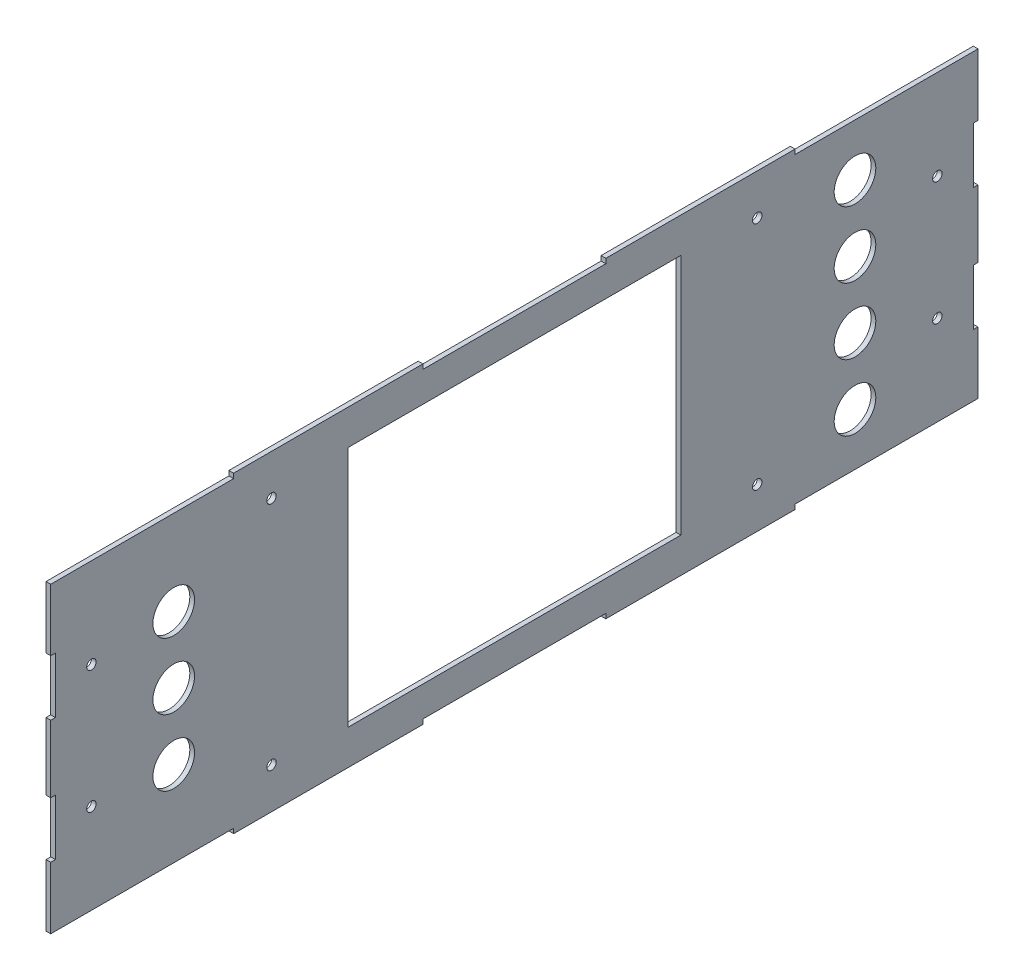
from build123d import *

# Parameters (mm, degrees)
BOSS_EXTRUDE1_DEPTH = 2.5
SKETCH2_R           = 2.5
SKETCH2_R_2         = 11
SKETCH2_W           = 2.5
SKETCH2_H           = 29.5
SKETCH2_W_2         = 176
SKETCH2_H_2         = 128
CUT_EXTRUDE1_DEPTH  = 3


with BuildPart() as part:
    # Sketch1 → Boss-Extrude1 (new body)
    with BuildSketch(Plane(origin=(0, 0, 0), x_dir=(0, 0, -1), z_dir=(1, 0, 0))):
        Polygon((-245, -80), (-148.333333333, -80), (-148.333333333, -82.5), (-48.333333333, -82.5), (-48.333333333, -80), (48.333333333, -80), (48.333333333, -82.5), (148.333333333, -82.5), (148.333333333, -80), (245, -80), (245, 80), (148.333333333, 80), (148.333333333, 82.5), (48.333333333, 82.5), (48.333333333, 80), (-48.333333333, 80), (-48.333333333, 82.5), (-148.333333333, 82.5), (-148.333333333, 80), (-245, 80), align=None)
    extrude(amount=BOSS_EXTRUDE1_DEPTH)

    # Sketch2 → Cut-Extrude1 (cut)
    with BuildSketch(Plane(origin=(2.5, 0, 0), x_dir=(0, 0, -1), z_dir=(1, 0, 0))):
        with Locations((-128.333333333, 61)):
            Circle(SKETCH2_R)
        with Locations((128.333333333, 61)):
            Circle(SKETCH2_R)
        with Locations((128.333333333, -61)):
            Circle(SKETCH2_R)
        with Locations((-128.333333333, -61)):
            Circle(SKETCH2_R)
        with Locations((-223.5, 32.5)):
            Circle(SKETCH2_R)
        with Locations((-223.5, -32.5)):
            Circle(SKETCH2_R)
        with Locations((223.5, 32.5)):
            Circle(SKETCH2_R)
        with Locations((223.5, -32.5)):
            Circle(SKETCH2_R)
        with Locations((-180, 35)):
            Circle(SKETCH2_R_2)
        with Locations((-180, 0)):
            Circle(SKETCH2_R_2)
        with Locations((-180, -35)):
            Circle(SKETCH2_R_2)
        with Locations((180, 17.5)):
            Circle(SKETCH2_R_2)
        with Locations((180, 52.5)):
            Circle(SKETCH2_R_2)
        with Locations((180, -17.5)):
            Circle(SKETCH2_R_2)
        with Locations((180, -52.5)):
            Circle(SKETCH2_R_2)
        with Locations((-243.75, 32.5)):
            Rectangle(SKETCH2_W, SKETCH2_H)
        with Locations((-243.75, -32.5)):
            Rectangle(SKETCH2_W, SKETCH2_H)
        with Locations((243.75, -32.5)):
            Rectangle(SKETCH2_W, SKETCH2_H)
        with Locations((243.75, 32.5)):
            Rectangle(SKETCH2_W, SKETCH2_H)
        Rectangle(SKETCH2_W_2, SKETCH2_H_2)
    extrude(amount=-CUT_EXTRUDE1_DEPTH, mode=Mode.SUBTRACT)


solid = part.part
